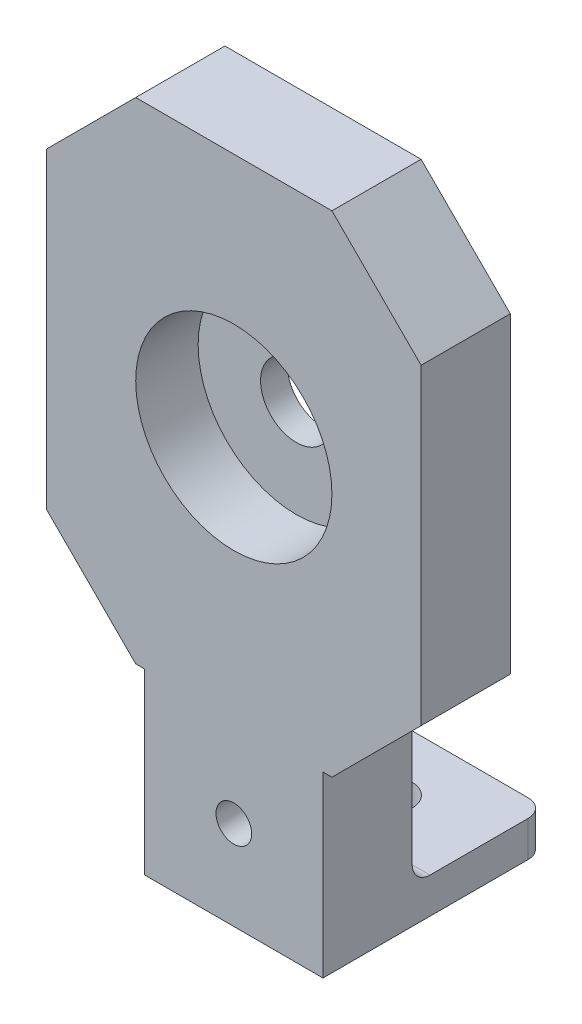
from build123d import *

# Parameters (mm, degrees)
ESTRUSIONE_ESTRUSIONE1_DEPTH = 10
SCHIZZO6_R                   = 11
TAGLIO_ESTRUSIONE4_DEPTH     = 7
SCHIZZO7_R                   = 4
TAGLIO_ESTRUSIONE5_DEPTH     = 4
SMUSSO2_SIZE                 = 10
SCHIZZO8_W                   = 20
SCHIZZO8_H                   = 4
ESTRUSIONE_ESTRUSIONE3_DEPTH = 15
SCHIZZO9_R                   = 2.5
TAGLIO_ESTRUSIONE6_DEPTH     = 35
RACCORDO1_R                  = 2
SCHIZZO10_R                  = 2
TAGLIO_ESTRUSIONE7_DEPTH     = 10


with BuildPart() as part:
    # Schizzo1 → Estrusione-Estrusione1 (new body)
    with BuildSketch(Plane.XY):
        Polygon((-10, -47.5), (10, -47.5), (10, -27.5), (21, -27.5), (21, 27.5), (-21, 27.5), (-21, -27.5), (-10, -27.5), align=None)
    extrude(amount=ESTRUSIONE_ESTRUSIONE1_DEPTH)

    # Schizzo6 → Taglio-Estrusione4 (cut)
    with BuildSketch(Plane.XY.offset(10)):
        Circle(SCHIZZO6_R)
    extrude(amount=-TAGLIO_ESTRUSIONE4_DEPTH, mode=Mode.SUBTRACT)

    # Schizzo7 → Taglio-Estrusione5 (cut, through all)
    with BuildSketch(Plane.XY.offset(3)):
        Circle(SCHIZZO7_R)
    extrude(amount=-TAGLIO_ESTRUSIONE5_DEPTH, mode=Mode.SUBTRACT)

    # Smusso2
    smusso2_edges = [part.edges().sort_by_distance(p)[0] for p in [
        (21, -27.5, 5),
        (-21, -27.5, 5),
        (-21, 27.5, 5),
        (21, 27.5, 5),
    ]]
    chamfer(smusso2_edges, length=SMUSSO2_SIZE)

    # Schizzo8 → Estrusione-Estrusione3 (add)
    with BuildSketch(Plane(origin=(0, 0, 0), x_dir=(-1, 0, 0), z_dir=(0, 0, -1))):
        with Locations((0, -45.5)):
            Rectangle(SCHIZZO8_W, SCHIZZO8_H)
    extrude(amount=ESTRUSIONE_ESTRUSIONE3_DEPTH)

    # Schizzo9 → Taglio-Estrusione6 (cut)
    with BuildSketch(Plane(origin=(0, -43.5, 0), x_dir=(1, 0, 0), z_dir=(0, 1, 0))):
        with Locations((0, 7.5)):
            Circle(SCHIZZO9_R)
    extrude(amount=-TAGLIO_ESTRUSIONE6_DEPTH, mode=Mode.SUBTRACT)

    # Raccordo1
    raccordo1_edges = [part.edges().sort_by_distance(p)[0] for p in [
        (0, -43.5, 0),
        (10, -45.5, -15),
        (-10, -45.5, -15),
    ]]
    fillet(raccordo1_edges, radius=RACCORDO1_R)

    # Schizzo10 → Taglio-Estrusione7 (cut)
    with BuildSketch(Plane(origin=(0, 0, 0), x_dir=(-1, 0, 0), z_dir=(0, 0, -1))):
        with Locations((0, -37.5)):
            Circle(SCHIZZO10_R)
    extrude(amount=-TAGLIO_ESTRUSIONE7_DEPTH, mode=Mode.SUBTRACT)


solid = part.part
